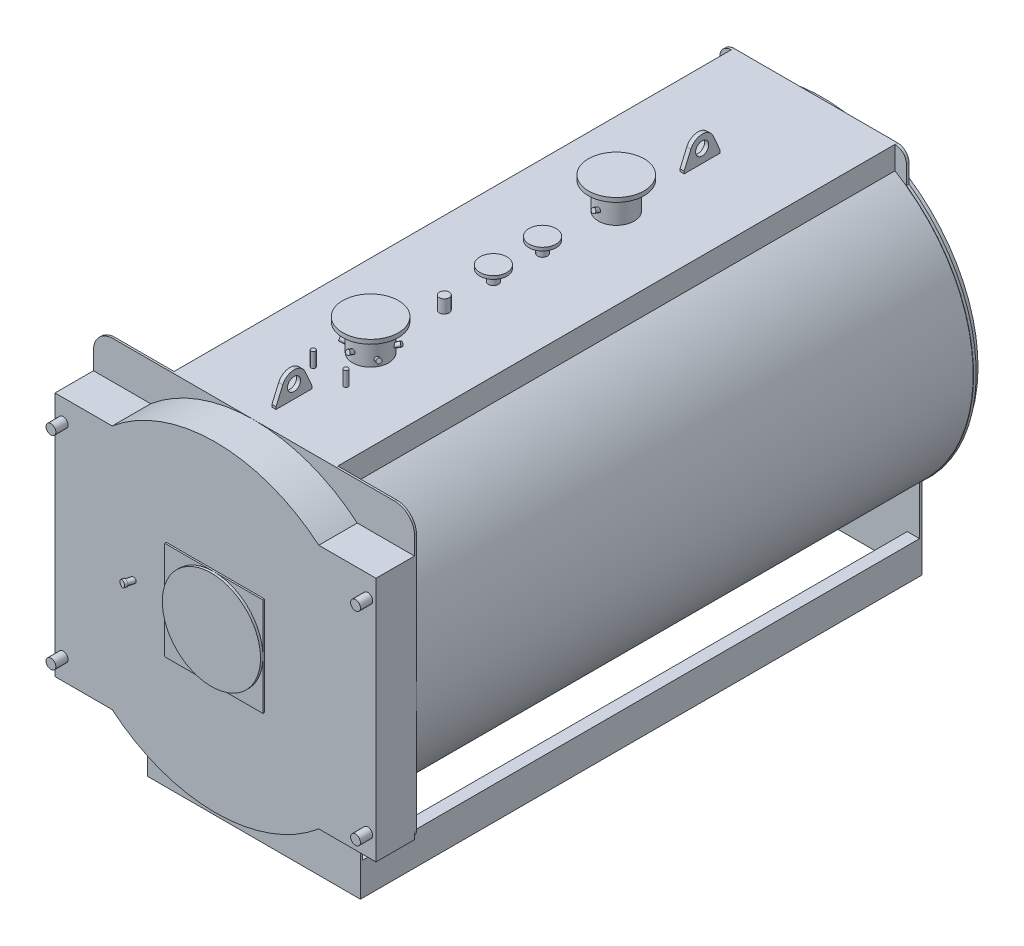
from build123d import *

# Parameters (mm, degrees)
PIASTRA_ANTERIORE_DEPTH       = 12
CORPO_DEPTH                   = 3402
PIASTRA_POSTERIORE_DEPTH      = 16
BASAMENTO_DEPTH               = 3402
ESTRUSIONE_ESTRUSIONE3_DEPTH  = 235
SCHIZZO8_W                    = 600
SCHIZZO8_H                    = 600
ESTRUSIONE_ESTRUSIONE4_DEPTH  = 10
SCHIZZO9_R                    = 300
ESTRUSIONE_ESTRUSIONE5_DEPTH  = 15
SCHIZZO12_R                   = 30
ESTRUSIONE_ESTRUSIONE6_DEPTH  = 75
SCHIZZO13_R                   = 109.55
ESTRUSIONE_ESTRUSIONE7_DEPTH  = 1170
SCHIZZO14_R                   = 170
ESTRUSIONE_ESTRUSIONE8_DEPTH  = 26
SCHIZZO13_3_R                 = 30.15
ESTRUSIONE_ESTRUSIONE9_DEPTH  = 1070
SCHIZZO15_R                   = 82.5
ESTRUSIONE_ESTRUSIONE10_DEPTH = 20
SCHIZZO13_4_R                 = 30.15
ESTRUSIONE_ESTRUSIONE11_DEPTH = 1060
SCHIZZO13_5_R                 = 13.35
ESTRUSIONE_ESTRUSIONE12_DEPTH = 1070
RIPETIZIONECIRCOLARE1_COUNT   = 3
SCHIZZO21_R                   = 24.15
ESTRUSIONE_ESTRUSIONE13_DEPTH = 149
SCHIZZO21_3_R                 = 24.15
ESTRUSIONE_ESTRUSIONE14_DEPTH = 50
SCHIZZO22_R                   = 75
ESTRUSIONE_ESTRUSIONE15_DEPTH = 16
SCHIZZO23_R                   = 40
GOLFARE_DEPTH                 = 12.5


with BuildPart() as part:
    # Schizzo1 → piastra anteriore (new body)
    with BuildSketch(Plane.XY):
        with BuildLine():
            Line((-860, 2210), (860, 2210))
            ThreePointArc((860, 2210), (944.852813742, 2174.852813742), (980, 2090))
            Line((980, 2090), (980, 520))
            ThreePointArc((980, 520), (968.284271247, 491.715728753), (940, 480))
            Line((940, 480), (650, 480))
            Line((650, 480), (650, 0))
            Line((650, 0), (-650, 0))
            Line((-650, 0), (-650, 480))
            Line((-650, 480), (-940, 480))
            ThreePointArc((-940, 480), (-968.284271247, 491.715728753), (-980, 520))
            Line((-980, 520), (-980, 2090))
            ThreePointArc((-980, 2090), (-944.852813742, 2174.852813742), (-860, 2210))
        make_face()
    extrude(amount=-PIASTRA_ANTERIORE_DEPTH)

    # Schizzo2 → corpo (add)
    with BuildSketch(Plane(origin=(0, 0, -12), x_dir=(-1, 0, 0), z_dir=(0, 0, -1))):
        with BuildLine():
            Line((500, 2069.944194575), (500, 2210))
            Line((500, 2210), (-500, 2210))
            Line((-500, 2210), (-500, 2069.944194575))
            ThreePointArc((-500, 2069.944194575), (0, 252.5), (500, 2069.944194575))
        make_face()
        with BuildLine():
            Line((490, 2064.239923523), (490, 2200))
            Line((490, 2200), (-490, 2200))
            Line((-490, 2200), (-490, 2064.239923523))
            ThreePointArc((-490, 2064.239923523), (0, 262.5), (490, 2064.239923523))
        make_face(mode=Mode.SUBTRACT)
    extrude(amount=CORPO_DEPTH)

    # Schizzo3 → piastra posteriore (add)
    with BuildSketch(Plane(origin=(0, 0, -3414), x_dir=(-1, 0, 0), z_dir=(0, 0, -1))):
        with BuildLine():
            Line((-570, 2027.182538695), (-570, 2140))
            ThreePointArc((-570, 2140), (-549.497474683, 2189.497474683), (-500, 2210))
            Line((-500, 2210), (500, 2210))
            ThreePointArc((500, 2210), (549.497474683, 2189.497474683), (570, 2140))
            Line((570, 2140), (570, 2027.182538695))
            ThreePointArc((570, 2027.182538695), (978.664129434, 1281.151947762), (650, 496.583338068))
            Line((650, 496.583338068), (650, 0))
            Line((650, 0), (-650, 0))
            Line((-650, 0), (-650, 496.583338068))
            ThreePointArc((-650, 496.583338068), (-978.664129434, 1281.151947762), (-570, 2027.182538695))
        make_face()
    extrude(amount=PIASTRA_POSTERIORE_DEPTH)

    # Schizzo5 → camera fumo (revolve)
    with BuildSketch(Plane(origin=(0, 0, 0), x_dir=(0, 0, -1), z_dir=(1, 0, 0)), mode=Mode.PRIVATE) as camera_fumo_sk:
        Polygon((3471, 1504), (3574, 1504), (3574, 1545), (3579, 1545), (3579, 1499), (3471, 1499), (3471, 1230), (3430, 1230), (3430, 2180), (3471, 2180), align=None)
    revolve(camera_fumo_sk.sketch.rotate(Axis((0, 1230, -3414), (0, 0, -1)), 90), axis=Axis((0, 1230, -3414), (0, 0, -1)))  # turned: the seam where the file's is

    # Schizzo6 → basamento (add)
    with BuildSketch(Plane(origin=(0, 0, -12), x_dir=(-1, 0, 0), z_dir=(0, 0, -1))):
        Polygon((-575, 0), (-650, 0), (-650, 200), (-575, 200), (-575, 190), (-640, 190), (-640, 10), (-575, 10), align=None)
    basamento = extrude(amount=BASAMENTO_DEPTH)

    # Specchia2: basamento across plane
    add(basamento.mirror(Plane(origin=(0, 0, 0), x_dir=(0, 0, 1), z_dir=(1, 0, 0))))

    # Schizzo7 → Estrusione-Estrusione3 (add)
    with BuildSketch(Plane.XY):
        with BuildLine():
            Line((630.793151516, 1980), (980, 1980))
            Line((980, 1980), (980, 480))
            Line((980, 480), (630.793151516, 480))
            ThreePointArc((630.793151516, 480), (0, 250), (-630.793151516, 480))
            Line((-630.793151516, 480), (-980, 480))
            Line((-980, 480), (-980, 1980))
            Line((-980, 1980), (-630.793151516, 1980))
            ThreePointArc((-630.793151516, 1980), (0, 2210), (630.793151516, 1980))
        make_face()
    extrude(amount=ESTRUSIONE_ESTRUSIONE3_DEPTH)

    # Schizzo8 → Estrusione-Estrusione4 (add)
    with BuildSketch(Plane.XY.offset(235)):
        with Locations((0, 1230)):
            Rectangle(SCHIZZO8_W, SCHIZZO8_H)
    extrude(amount=ESTRUSIONE_ESTRUSIONE4_DEPTH)

    # Schizzo9 → Estrusione-Estrusione5 (add)
    with BuildSketch(Plane.XY.offset(245)):
        with Locations((0, 1230)):
            Circle(SCHIZZO9_R)
    extrude(amount=ESTRUSIONE_ESTRUSIONE5_DEPTH)

    # Schizzo11 → Rivoluzione2 (revolve)
    with BuildSketch(Plane(origin=(0, 1230, 0), x_dir=(1, 0, 0), z_dir=(0, 1, 0)), mode=Mode.PRIVATE) as rivoluzione2_sk:
        Polygon((-515.868693957, -288.251490803), (-497.762357162, -220.677721947), (-481.631395863, -225), (-495.596627936, -277.118955636), (-492.409072709, -277.973058485), (-496.550177431, -293.427871705), align=None)
    revolve(rivoluzione2_sk.sketch.rotate(Axis((-501.6, 1230, 235), (-0.258819045, 0, 0.965925826)), 180), axis=Axis((-501.6, 1230, 235), (-0.258819045, 0, 0.965925826)))  # turned: the seam where the file's is

    # Schizzo12 → Estrusione-Estrusione6 (add)
    with BuildSketch(Plane.XY.offset(235)):
        with Locations((-930, 1850)):
            Circle(SCHIZZO12_R)
        with Locations(Location((930, 1850, 0), (0, 0, 180))):  # turned: the seam where the file's is
            Circle(SCHIZZO12_R)
        with Locations((930, 610)):
            Circle(SCHIZZO12_R)
        with Locations(Location((-930, 610, 0), (0, 0, 180))):  # turned: the seam where the file's is
            Circle(SCHIZZO12_R)
    extrude(amount=ESTRUSIONE_ESTRUSIONE6_DEPTH)

    # Schizzo13 → Estrusione-Estrusione7 (add)
    with BuildSketch(Plane(origin=(0, 1230, 0), x_dir=(1, 0, 0), z_dir=(0, 1, 0))):
        with Locations(Location((0, 712, 0), (0, 0, 270))):  # turned: the seam where the file's is
            Circle(SCHIZZO13_R)
        with Locations(Location((0, 2212, 0), (0, 0, 270))):  # turned: the seam where the file's is
            Circle(SCHIZZO13_R)
    extrude(amount=ESTRUSIONE_ESTRUSIONE7_DEPTH)

    # Schizzo14 → Estrusione-Estrusione8 (add)
    with BuildSketch(Plane(origin=(0, 2400, 0), x_dir=(1, 0, 0), z_dir=(0, 1, 0))):
        with Locations(Location((0, 712, 0), (0, 0, 270))):  # turned: the seam where the file's is
            Circle(SCHIZZO14_R)
        with Locations(Location((0, 2212, 0), (0, 0, 270))):  # turned: the seam where the file's is
            Circle(SCHIZZO14_R)
    extrude(amount=-ESTRUSIONE_ESTRUSIONE8_DEPTH)

    # Schizzo13_3 → Estrusione-Estrusione9 (add)
    with BuildSketch(Plane(origin=(0, 1230, 0), x_dir=(1, 0, 0), z_dir=(0, 1, 0))):
        with Locations(Location((0, 1762, 0), (0, 0, 270))):  # turned: the seam where the file's is
            Circle(SCHIZZO13_3_R)
        with Locations(Location((0, 1462, 0), (0, 0, 270))):  # turned: the seam where the file's is
            Circle(SCHIZZO13_3_R)
    extrude(amount=ESTRUSIONE_ESTRUSIONE9_DEPTH)

    # Schizzo15 → Estrusione-Estrusione10 (add)
    with BuildSketch(Plane(origin=(0, 2300, 0), x_dir=(1, 0, 0), z_dir=(0, 1, 0))):
        with Locations(Location((0, 1762, 0), (0, 0, 270))):  # turned: the seam where the file's is
            Circle(SCHIZZO15_R)
        with Locations(Location((0, 1462, 0), (0, 0, 270))):  # turned: the seam where the file's is
            Circle(SCHIZZO15_R)
    extrude(amount=-ESTRUSIONE_ESTRUSIONE10_DEPTH)

    # Schizzo13_4 → Estrusione-Estrusione11 (add)
    with BuildSketch(Plane(origin=(0, 1230, 0), x_dir=(1, 0, 0), z_dir=(0, 1, 0))):
        with Locations(Location((0, 1162, 0), (0, 0, 270))):  # turned: the seam where the file's is
            Circle(SCHIZZO13_4_R)
    extrude(amount=ESTRUSIONE_ESTRUSIONE11_DEPTH)

    # Schizzo13_5 → Estrusione-Estrusione12 (add)
    with BuildSketch(Plane(origin=(0, 1230, 0), x_dir=(1, 0, 0), z_dir=(0, 1, 0))):
        with Locations(Location((-100, 462, 0), (0, 0, 270))):  # turned: the seam where the file's is
            Circle(SCHIZZO13_5_R)
        with Locations(Location((100, 462, 0), (0, 0, 270))):  # turned: the seam where the file's is
            Circle(SCHIZZO13_5_R)
    extrude(amount=ESTRUSIONE_ESTRUSIONE12_DEPTH)

    # Schizzo16 → Rivoluzione3 (revolve)
    with BuildSketch(Plane(origin=(0, 0, 0), x_dir=(0, 0, -1), z_dir=(1, 0, 0))):
        Polygon((2073.149829072, 2280.664390077), (2077.75, 2293.303255826), (2124.734631039, 2276.20224866), (2120.134460112, 2263.56338291), align=None)
    revolve(axis=Axis((0, 2270, -2102.45), (0, 0.342020143, 0.939692621)))

    # Schizzo17 → Rivoluzione4 (revolve)
    with BuildSketch(Plane(origin=(0, 0, 0), x_dir=(0, 0, -1), z_dir=(1, 0, 0))):
        Polygon((573.149829072, 2280.664390077), (577.75, 2293.303255826), (624.734631039, 2276.20224866), (620.134460112, 2263.56338291), align=None)
    rivoluzione4 = revolve(axis=Axis((0, 2270, -602.45), (0, 0.342020143, 0.939692621)))

    # Schizzo18 → Rivoluzione5 (revolve)
    with BuildSketch(Plane(origin=(0, 0, 0), x_dir=(0, 0, -1), z_dir=(1, 0, 0)), mode=Mode.PRIVATE) as rivoluzione5_sk:
        Polygon((850.850170928, 2260.664390077), (846.25, 2273.303255826), (799.265368961, 2256.20224866), (803.865539888, 2243.56338291), align=None)
    rivoluzione5 = revolve(rivoluzione5_sk.sketch.rotate(Axis((0, 2250, -821.55), (0, 0.342020143, -0.939692621)), 180), axis=Axis((0, 2250, -821.55), (0, 0.342020143, -0.939692621)))  # turned: the seam where the file's is

    # RipetizioneCircolare1: Rivoluzione4, Rivoluzione5 ×3 about axis
    ripetizionecircolare1_axis = Axis((0, 0, -712), (0, 1, 0))
    add([rivoluzione4.rotate(ripetizionecircolare1_axis, i * 360 / RIPETIZIONECIRCOLARE1_COUNT) for i in range(1, RIPETIZIONECIRCOLARE1_COUNT)])
    add([rivoluzione5.rotate(ripetizionecircolare1_axis, i * 360 / RIPETIZIONECIRCOLARE1_COUNT) for i in range(1, RIPETIZIONECIRCOLARE1_COUNT)])

    # Schizzo21 → Estrusione-Estrusione13 (add)
    with BuildSketch(Plane(origin=(0, 0, -3430), x_dir=(-1, 0, 0), z_dir=(0, 0, -1))):
        with Locations((0, 125)):
            Circle(SCHIZZO21_R)
    extrude(amount=ESTRUSIONE_ESTRUSIONE13_DEPTH)

    # Schizzo21_3 → Estrusione-Estrusione14 (add)
    with BuildSketch(Plane(origin=(0, 0, -3430), x_dir=(-1, 0, 0), z_dir=(0, 0, -1))):
        with Locations(Location((0, 260, 0), (0, 0, 123.688228426))):  # turned: the seam where the file's is
            Circle(SCHIZZO21_3_R)
    extrude(amount=ESTRUSIONE_ESTRUSIONE14_DEPTH)

    # Schizzo22 → Estrusione-Estrusione15 (add)
    with BuildSketch(Plane(origin=(0, 0, -3579), x_dir=(-1, 0, 0), z_dir=(0, 0, -1))):
        with Locations((0, 125)):
            Circle(SCHIZZO22_R)
    extrude(amount=-ESTRUSIONE_ESTRUSIONE15_DEPTH)

    # Schizzo23 → golfare (add, symmetric)
    with BuildSketch(Plane(origin=(0, 0, 0), x_dir=(0, 0, -1), z_dir=(1, 0, 0))):
        with BuildLine():
            Line((122, 2145), (122, 2225))
            Line((122, 2225), (163.208335614, 2319.878201268))
            ThreePointArc((163.208335614, 2319.878201268), (232, 2365), (300.791664386, 2319.878201268))
            Line((300.791664386, 2319.878201268), (342, 2225))
            Line((342, 2225), (342, 2145))
            Line((342, 2145), (122, 2145))
        make_face()
        with Locations((232, 2290)):
            Circle(SCHIZZO23_R, mode=Mode.SUBTRACT)
        with BuildLine():
            Line((2614, 2145), (2614, 2225))
            Line((2614, 2225), (2655.208335614, 2319.878201268))
            ThreePointArc((2655.208335614, 2319.878201268), (2724, 2365), (2792.791664386, 2319.878201268))
            Line((2792.791664386, 2319.878201268), (2834, 2225))
            Line((2834, 2225), (2834, 2145))
            Line((2834, 2145), (2614, 2145))
        make_face()
        with Locations((2724, 2290)):
            Circle(SCHIZZO23_R, mode=Mode.SUBTRACT)
    extrude(amount=GOLFARE_DEPTH, both=True)


solid = part.part
